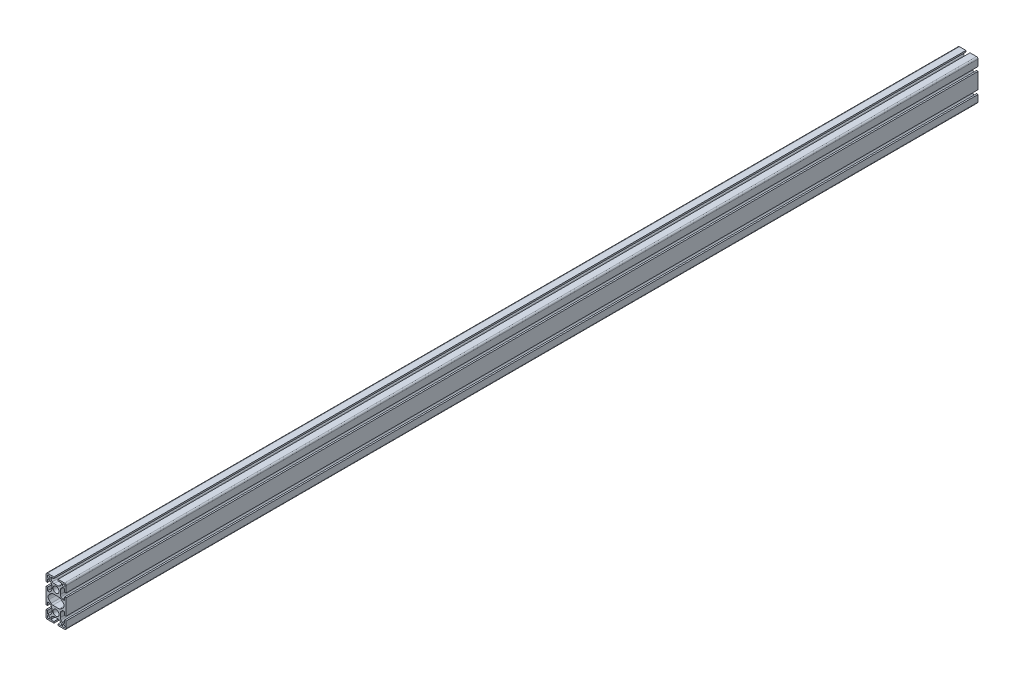
from build123d import *

# Parameters (mm, degrees)
SKETCH1_R           = 2.5
SKETCH1_R_2         = 6
BOSS_EXTRUDE1_DEPTH = 1820


with BuildPart() as part:
    # Sketch1 → Boss-Extrude1 (new body)
    with BuildSketch(Plane.XY):
        with BuildLine():
            Line((-17, -40), (-4.1, -40))
            Line((-4.1, -40), (-4.1, -37))
            Line((-4.1, -37), (-10.5, -37))
            Line((-10.5, -37), (-10.5, -33.6627417))
            ThreePointArc((-10.5, -33.6627417), (-10.378207252, -33.050448208), (-10.03137085, -32.53137085))
            Line((-10.03137085, -32.53137085), (-7.464466094, -29.964466094))
            ThreePointArc((-7.464466094, -29.964466094), (-5.84234935, -28.880602337), (-3.928932188, -28.5))
            Line((-3.928932188, -28.5), (3.928932188, -28.5))
            ThreePointArc((3.928932188, -28.5), (5.84234935, -28.880602337), (7.464466094, -29.964466094))
            Line((7.464466094, -29.964466094), (10.03137085, -32.53137085))
            ThreePointArc((10.03137085, -32.53137085), (10.378207252, -33.050448208), (10.5, -33.6627417))
            Line((10.5, -33.6627417), (10.5, -37))
            Line((10.5, -37), (4.1, -37))
            Line((4.1, -37), (4.1, -40))
            Line((4.1, -40), (17, -40))
            ThreePointArc((17, -40), (19.121320344, -39.121320344), (20, -37))
            Line((20, -37), (20, -24.1))
            Line((20, -24.1), (17, -24.1))
            Line((17, -24.1), (17, -30.5))
            Line((17, -30.5), (13.6627417, -30.5))
            ThreePointArc((13.6627417, -30.5), (13.050448208, -30.378207252), (12.53137085, -30.03137085))
            Line((12.53137085, -30.03137085), (9.964466094, -27.464466094))
            ThreePointArc((9.964466094, -27.464466094), (8.880602337, -25.84234935), (8.5, -23.928932188))
            Line((8.5, -23.928932188), (8.5, -16.071067812))
            ThreePointArc((8.5, -16.071067812), (8.880602337, -14.15765065), (9.964466094, -12.535533906))
            Line((9.964466094, -12.535533906), (12.53137085, -9.96862915))
            ThreePointArc((12.53137085, -9.96862915), (13.050448208, -9.621792748), (13.6627417, -9.5))
            Line((13.6627417, -9.5), (17, -9.5))
            Line((17, -9.5), (17, -15.9))
            Line((17, -15.9), (20, -15.9))
            Line((20, -15.9), (20, 15.9))
            Line((20, 15.9), (17, 15.9))
            Line((17, 15.9), (17, 9.5))
            Line((17, 9.5), (13.6627417, 9.5))
            ThreePointArc((13.6627417, 9.5), (13.050448208, 9.621792748), (12.53137085, 9.96862915))
            Line((12.53137085, 9.96862915), (9.964466094, 12.535533906))
            ThreePointArc((9.964466094, 12.535533906), (8.880602337, 14.15765065), (8.5, 16.071067812))
            Line((8.5, 16.071067812), (8.5, 23.928932188))
            ThreePointArc((8.5, 23.928932188), (8.880602337, 25.84234935), (9.964466094, 27.464466094))
            Line((9.964466094, 27.464466094), (12.53137085, 30.03137085))
            ThreePointArc((12.53137085, 30.03137085), (13.050448208, 30.378207252), (13.6627417, 30.5))
            Line((13.6627417, 30.5), (17, 30.5))
            Line((17, 30.5), (17, 24.1))
            Line((17, 24.1), (20, 24.1))
            Line((20, 24.1), (20, 37))
            ThreePointArc((20, 37), (19.121320344, 39.121320344), (17, 40))
            Line((17, 40), (4.1, 40))
            Line((4.1, 40), (4.1, 37))
            Line((4.1, 37), (10.5, 37))
            Line((10.5, 37), (10.5, 33.6627417))
            ThreePointArc((10.5, 33.6627417), (10.378207252, 33.050448208), (10.03137085, 32.53137085))
            Line((10.03137085, 32.53137085), (7.464466094, 29.964466094))
            ThreePointArc((7.464466094, 29.964466094), (5.84234935, 28.880602337), (3.928932188, 28.5))
            Line((3.928932188, 28.5), (-3.928932188, 28.5))
            ThreePointArc((-3.928932188, 28.5), (-5.84234935, 28.880602337), (-7.464466094, 29.964466094))
            Line((-7.464466094, 29.964466094), (-10.03137085, 32.53137085))
            ThreePointArc((-10.03137085, 32.53137085), (-10.378207252, 33.050448208), (-10.5, 33.6627417))
            Line((-10.5, 33.6627417), (-10.5, 37))
            Line((-10.5, 37), (-4.1, 37))
            Line((-4.1, 37), (-4.1, 40))
            Line((-4.1, 40), (-17, 40))
            ThreePointArc((-17, 40), (-19.121320344, 39.121320344), (-20, 37))
            Line((-20, 37), (-20, 24.1))
            Line((-20, 24.1), (-17, 24.1))
            Line((-17, 24.1), (-17, 30.5))
            Line((-17, 30.5), (-13.6627417, 30.5))
            ThreePointArc((-13.6627417, 30.5), (-13.050448208, 30.378207252), (-12.53137085, 30.03137085))
            Line((-12.53137085, 30.03137085), (-9.964466094, 27.464466094))
            ThreePointArc((-9.964466094, 27.464466094), (-8.880602337, 25.84234935), (-8.5, 23.928932188))
            Line((-8.5, 23.928932188), (-8.5, 16.071067812))
            ThreePointArc((-8.5, 16.071067812), (-8.880602337, 14.15765065), (-9.964466094, 12.535533906))
            Line((-9.964466094, 12.535533906), (-12.53137085, 9.96862915))
            ThreePointArc((-12.53137085, 9.96862915), (-13.050448208, 9.621792748), (-13.6627417, 9.5))
            Line((-13.6627417, 9.5), (-17, 9.5))
            Line((-17, 9.5), (-17, 15.9))
            Line((-17, 15.9), (-20, 15.9))
            Line((-20, 15.9), (-20, -15.9))
            Line((-20, -15.9), (-17, -15.9))
            Line((-17, -15.9), (-17, -9.5))
            Line((-17, -9.5), (-13.6627417, -9.5))
            ThreePointArc((-13.6627417, -9.5), (-13.050448208, -9.621792748), (-12.53137085, -9.96862915))
            Line((-12.53137085, -9.96862915), (-9.964466094, -12.535533906))
            ThreePointArc((-9.964466094, -12.535533906), (-8.880602337, -14.15765065), (-8.5, -16.071067812))
            Line((-8.5, -16.071067812), (-8.5, -23.928932188))
            ThreePointArc((-8.5, -23.928932188), (-8.880602337, -25.84234935), (-9.964466094, -27.464466094))
            Line((-9.964466094, -27.464466094), (-12.53137085, -30.03137085))
            ThreePointArc((-12.53137085, -30.03137085), (-13.050448208, -30.378207252), (-13.6627417, -30.5))
            Line((-13.6627417, -30.5), (-17, -30.5))
            Line((-17, -30.5), (-17, -24.1))
            Line((-17, -24.1), (-20, -24.1))
            Line((-20, -24.1), (-20, -37))
            ThreePointArc((-20, -37), (-19.121320344, -39.121320344), (-17, -40))
        make_face()
        with Locations((15, 35)):
            Circle(SKETCH1_R, mode=Mode.SUBTRACT)
        with Locations((15, -35)):
            Circle(SKETCH1_R, mode=Mode.SUBTRACT)
        with Locations((0, 20)):
            Circle(SKETCH1_R_2, mode=Mode.SUBTRACT)
        with Locations((0, -20)):
            Circle(SKETCH1_R_2, mode=Mode.SUBTRACT)
        with Locations((-15, 35)):
            Circle(SKETCH1_R, mode=Mode.SUBTRACT)
        with Locations((-15, -35)):
            Circle(SKETCH1_R, mode=Mode.SUBTRACT)
        with BuildLine():
            Line((-14.242640687, -4.242640687), (-9.949747468, -8.535533906))
            ThreePointArc((-9.949747468, -8.535533906), (-8.327630724, -9.619397663), (-6.414213562, -10))
            Line((-6.414213562, -10), (6.414213562, -10))
            ThreePointArc((6.414213562, -10), (8.327630724, -9.619397663), (9.949747468, -8.535533906))
            Line((9.949747468, -8.535533906), (14.242640687, -4.242640687))
            ThreePointArc((14.242640687, -4.242640687), (16, 0), (14.242640687, 4.242640687))
            Line((14.242640687, 4.242640687), (9.949747468, 8.535533906))
            ThreePointArc((9.949747468, 8.535533906), (8.327630724, 9.619397663), (6.414213562, 10))
            Line((6.414213562, 10), (-6.414213562, 10))
            ThreePointArc((-6.414213562, 10), (-8.327630724, 9.619397663), (-9.949747468, 8.535533906))
            Line((-9.949747468, 8.535533906), (-14.242640687, 4.242640687))
            ThreePointArc((-14.242640687, 4.242640687), (-16, 0), (-14.242640687, -4.242640687))
        make_face(mode=Mode.SUBTRACT)
    extrude(amount=-BOSS_EXTRUDE1_DEPTH)


solid = part.part
